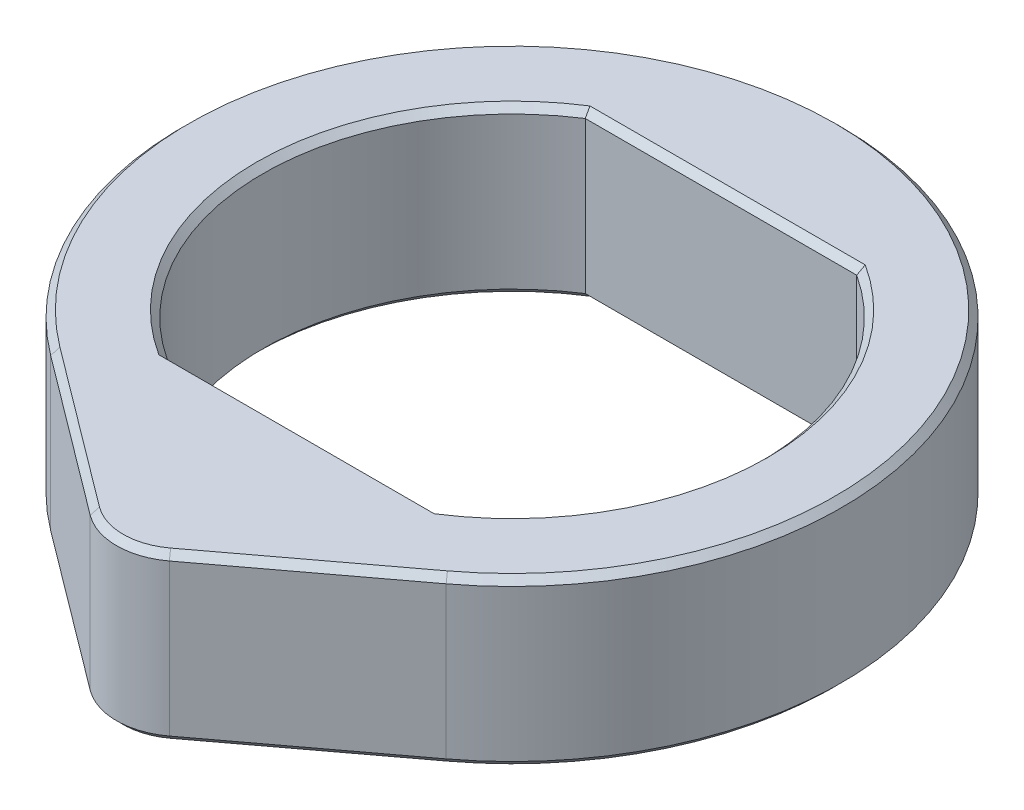
from build123d import *

# Parameters (mm, degrees)
SKETCH1_R           = 10
SKETCH1_R_2         = 7.56
BOSS_EXTRUDE1_DEPTH = 2.5
BOSS_EXTRUDE2_DEPTH = 5
BOSS_EXTRUDE3_DEPTH = 5
CHAMFER1_SIZE       = 0.2


with BuildPart() as part:
    # Sketch1 → Boss-Extrude1 (new body, symmetric)
    with BuildSketch(Plane(origin=(0, 0, 0), x_dir=(1, 0, 0), z_dir=(0, 1, 0))):
        Circle(SKETCH1_R)
        Circle(SKETCH1_R_2, mode=Mode.SUBTRACT)
    extrude(amount=BOSS_EXTRUDE1_DEPTH, both=True)

    # Sketch2 → Boss-Extrude2 (add)
    with BuildSketch(Plane(origin=(0, 2.5, 0), x_dir=(1, 0, 0), z_dir=(0, 1, 0))):
        with BuildLine():
            Line((-4.118009228, -6.34), (4.118009228, -6.34))
            ThreePointArc((4.118009228, -6.34), (0, -7.56), (-4.118009228, -6.34))
        make_face()
        with BuildLine():
            Line((-4.118009228, 6.34), (4.118009228, 6.34))
            ThreePointArc((4.118009228, 6.34), (0, 7.56), (-4.118009228, 6.34))
        make_face()
    extrude(amount=-BOSS_EXTRUDE2_DEPTH)

    # Sketch3 → Boss-Extrude3 (add)
    with BuildSketch(Plane(origin=(0, 2.5, 0), x_dir=(1, 0, 0), z_dir=(0, 1, 0))):
        with BuildLine():
            Line((-6, -8), (-1.2, -11.6))
            ThreePointArc((-1.2, -11.6), (0, -12), (1.2, -11.6))
            Line((1.2, -11.6), (6, -8))
            ThreePointArc((6, -8), (0, -10), (-6, -8))
        make_face()
    extrude(amount=-BOSS_EXTRUDE3_DEPTH)

    # Chamfer1
    chamfer1_edges = [part.edges().sort_by_distance(p)[0] for p in [
        (-7.56, 2.5, 0),
        (-7.56, -2.5, 0),
        (0, 2.5, 6.34),
        (0, -2.5, 6.34),
        (0, 2.5, -6.34),
        (0, -2.5, -6.34),
        (0, -2.5, -10),
        (-3.6, 2.5, 9.8),
        (0, 2.5, 12),
        (3.6, 2.5, 9.8),
        (3.6, -2.5, 9.8),
        (0, -2.5, 12),
        (-3.6, -2.5, 9.8),
        (0, 2.5, -10),
        (7.56, -2.5, 0),
        (7.56, 2.5, 0),
    ]]
    chamfer(chamfer1_edges, length=CHAMFER1_SIZE)


solid = part.part
